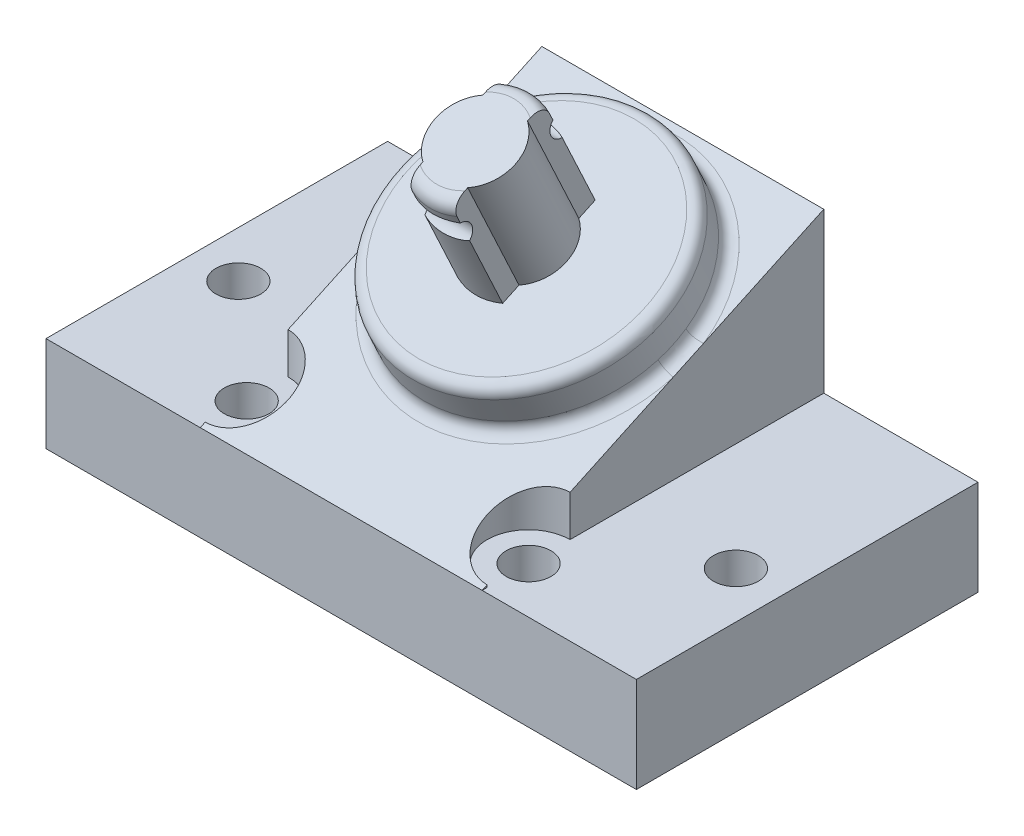
from build123d import *

# Parameters (mm, degrees)
BOSS_EXTRUDE1_DEPTH = 7.5
SKETCH8_W           = 35.6
SKETCH8_H           = 5.75
BOSS_EXTRUDE4_DEPTH = 5.6
BOSS_EXTRUDE5_DEPTH = 8.5
SKETCH3_R           = 7.86
BOSS_EXTRUDE2_DEPTH = 3
FILLET4_R           = 0.7
BOSS_EXTRUDE3_DEPTH = 7.32
SKETCH6_R           = 0.715
CUT_EXTRUDE2_DEPTH  = 20.15
FILLET5_R           = 0.8
SKETCH9_R           = 1.35
CUT_EXTRUDE3_DEPTH  = 6.75
SKETCH12_R          = 2.5
CUT_EXTRUDE4_DEPTH  = 17.312326385


with BuildPart() as part:
    # Sketch1 → Boss-Extrude1 (new body, symmetric)
    with BuildSketch(Plane.XY):
        Polygon((-17.8, 5.75), (17.8, 5.75), (17.8, 0), (12.2, 0), (12.2, 2.75), (-12.2, 2.75), (-12.2, 0), (-17.8, 0), align=None)
    extrude(amount=BOSS_EXTRUDE1_DEPTH, both=True)

    # Sketch8 → Boss-Extrude4 (add)
    with BuildSketch(Plane.XY.offset(7.5)):
        with Locations((0, 2.875)):
            Rectangle(SKETCH8_W, SKETCH8_H)
    extrude(amount=BOSS_EXTRUDE4_DEPTH)

    # Sketch11 → Boss-Extrude5 (add, symmetric)
    with BuildSketch(Plane(origin=(0, 0, 0), x_dir=(0, 0, -1), z_dir=(1, 0, 0))):
        Polygon((-13.1, 5.75), (7.5, 15.355937758), (7.5, 5.75), align=None)
    extrude(amount=BOSS_EXTRUDE5_DEPTH, both=True)

    # Sketch3 → Boss-Extrude2 (add)
    with BuildSketch(Plane(origin=(0, -0.825909529, 27.202083493), x_dir=(1, 0, 0), z_dir=(0, -0.906307787, -0.422618262))):
        with Locations((0, -29.289512668)):
            Circle(SKETCH3_R)
    extrude(amount=-BOSS_EXTRUDE2_DEPTH)

    # Fillet4
    fillet4_edges = [part.edges().sort_by_distance(p)[0] for p in [
        (-7.86, 14.271296763, 1.924624869),
        (-7.86, 11.552373402, 0.656770083),
    ]]
    fillet(fillet4_edges, radius=FILLET4_R)

    # Sketch5 → Boss-Extrude3 (add)
    with BuildSketch(Plane(origin=(0, 12.459528841, 5.809973716), x_dir=(1, 0, 0), z_dir=(0, 0.906307787, 0.422618262))):
        with BuildLine():
            Line((1.35, 6.277366133), (1.35, 7.363873413))
            ThreePointArc((1.35, 7.363873413), (0, 7.647008125), (-1.35, 7.363873413))
            Line((-1.35, 7.363873413), (-1.35, 6.277366133))
            ThreePointArc((-1.35, 6.277366133), (-2.405, 4.287008125), (-1.35, 2.296650117))
            Line((-1.35, 2.296650117), (-1.35, 1.210142838))
            ThreePointArc((-1.35, 1.210142838), (0, 0.927008125), (1.35, 1.210142838))
            Line((1.35, 1.210142838), (1.35, 2.296650117))
            ThreePointArc((1.35, 2.296650117), (2.405, 4.287008125), (1.35, 6.277366133))
        make_face()
    extrude(amount=BOSS_EXTRUDE3_DEPTH)

    # Sketch6 → Cut-Extrude2 (cut, through all)
    with BuildSketch(Plane(origin=(1.35, 0, 0), x_dir=(0, 0, -1), z_dir=(1, 0, 0))):
        with Locations((-7.239279099, 17.71817222)):
            Circle(SKETCH6_R)
        with Locations((-1.14889077, 20.558166939)):
            Circle(SKETCH6_R)
    extrude(amount=-CUT_EXTRUDE2_DEPTH, mode=Mode.SUBTRACT)

    # Fillet5
    fillet5_edges = [part.edges().sort_by_distance(p)[0] for p in [
        (0, 19.485472405, 8.063384709),
        (0, 22.325467124, 1.97299638),
    ]]
    fillet(fillet5_edges, radius=FILLET5_R)

    # Sketch9 → Cut-Extrude3 (cut, through all)
    with BuildSketch(Plane(origin=(0, 5.75, 0), x_dir=(1, 0, 0), z_dir=(0, 1, 0))):
        with Locations((-8.5, -10.3)):
            Circle(SKETCH9_R)
        with Locations((-15, -4.3)):
            Circle(SKETCH9_R)
        with Locations((8.5, -10.3)):
            Circle(SKETCH9_R)
        with Locations((15, -4.3)):
            Circle(SKETCH9_R)
    extrude(amount=-CUT_EXTRUDE3_DEPTH, mode=Mode.SUBTRACT)

    # Sketch12 → Cut-Extrude4 (cut, through all)
    with BuildSketch(Plane(origin=(0, 5.75, 0), x_dir=(-1, 0, 0), z_dir=(0, 1, 0))):
        with Locations((8.5, 10.3)):
            Circle(SKETCH12_R)
        with Locations((-8.5, 10.3)):
            Circle(SKETCH12_R)
    extrude(amount=CUT_EXTRUDE4_DEPTH, mode=Mode.SUBTRACT)


solid = part.part
